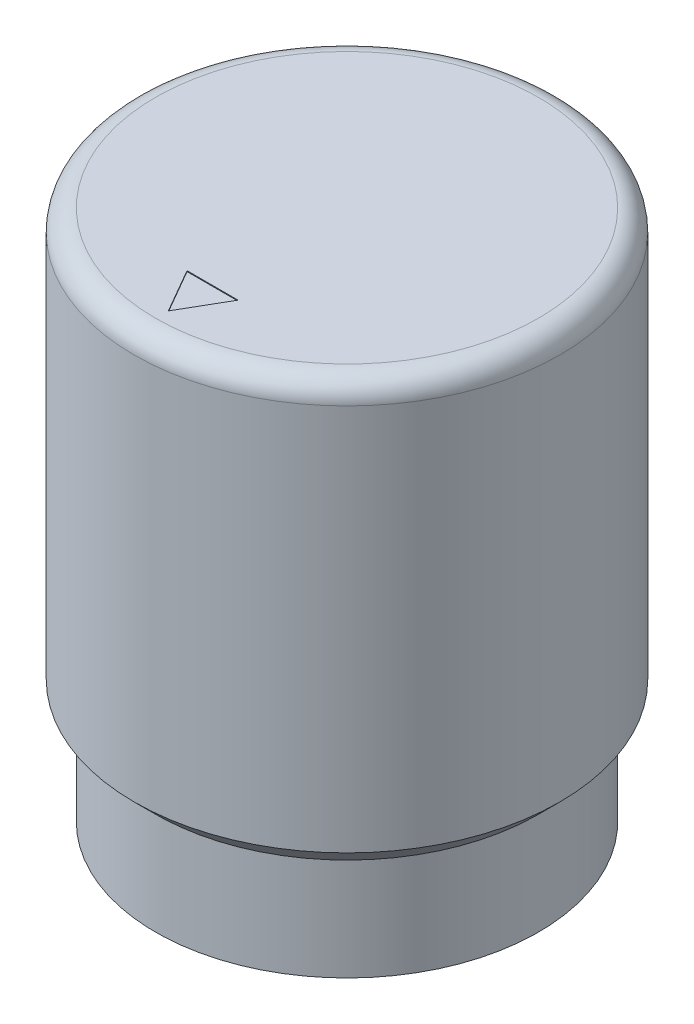
from build123d import *

# Parameters (mm, degrees)
F_1_8_0_125_DIAMETER_HOLE1_D     = 3.175
F_1_8_0_125_DIAMETER_HOLE1_DEPTH = 12.954
F_1_8_0_125_DIAMETER_HOLE1_TIP   = 0.953866233
F_6_32_TAPPED_HOLE1_D            = 2.7051
F_6_32_TAPPED_HOLE1_DEPTH        = 6.349
F_6_32_TAPPED_HOLE1_TIP          = 0.81269403
FILLET1_R                        = 0.635
CUT_EXTRUDE1_DEPTH               = 0.0254


with BuildPart() as part:
    # Sketch1 → Revolve1 (revolve)
    with BuildSketch(Plane.XY):
        Polygon((0, 15.875), (6.35, 15.875), (6.35, 3.683), (5.715, 3.048), (5.715, 0), (4.7625, 0), (4.7625, 3.9878), (0, 3.9878), align=None)
    revolve(axis=Axis((0, 0, 0), (0, 1, 0)))

    # 1/8 (0.125) Diameter Hole1
    with Locations(Plane(origin=(0, 0, 0), x_dir=(-1, 0, 0), z_dir=(0, -1, 0))):
        with Locations((0, 0)):
            Hole(F_1_8_0_125_DIAMETER_HOLE1_D / 2, depth=F_1_8_0_125_DIAMETER_HOLE1_DEPTH)
            with Locations((0, 0, -(F_1_8_0_125_DIAMETER_HOLE1_DEPTH + F_1_8_0_125_DIAMETER_HOLE1_TIP / 2))):  # 118° drill point
                Cone(0, F_1_8_0_125_DIAMETER_HOLE1_D / 2, F_1_8_0_125_DIAMETER_HOLE1_TIP, mode=Mode.SUBTRACT)

    # #6-32 Tapped Hole1
    with Locations(Plane(origin=(0, 0, -6.35), x_dir=(-1, 0, 0), z_dir=(0, 0, -1))):
        with Locations((0, 7.239)):
            Hole(F_6_32_TAPPED_HOLE1_D / 2, depth=F_6_32_TAPPED_HOLE1_DEPTH)
            with Locations((0, 0, -(F_6_32_TAPPED_HOLE1_DEPTH + F_6_32_TAPPED_HOLE1_TIP / 2))):  # 118° drill point
                Cone(0, F_6_32_TAPPED_HOLE1_D / 2, F_6_32_TAPPED_HOLE1_TIP, mode=Mode.SUBTRACT)

    # Fillet1
    fillet1_edges = [part.edges().sort_by_distance(p)[0] for p in [
        (-6.35, 15.875, 0),
    ]]
    fillet(fillet1_edges, radius=FILLET1_R)

    # Sketch6 → Cut-Extrude1 (cut)
    with BuildSketch(Plane(origin=(0, 15.875, 0), x_dir=(1, 0, 0), z_dir=(0, 1, 0))):
        Polygon((0, -5.334), (-0.762, -4.014177285), (0.762, -4.014177285), align=None)
    extrude(amount=-CUT_EXTRUDE1_DEPTH, mode=Mode.SUBTRACT)


solid = part.part
